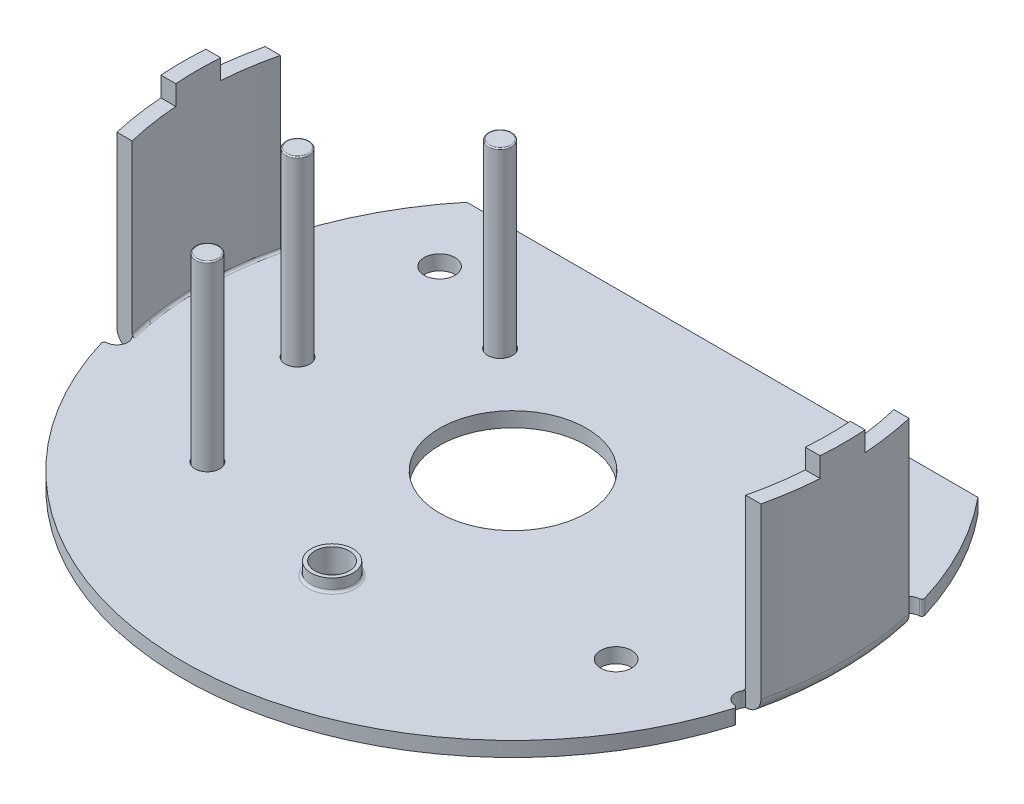
from build123d import *

# Parameters (mm, degrees)
SKETCH_1_R          = 13.375
EXTRUDE_1_DEPTH     = 7.85
SHELL_1_T           = -0.6
CUT_EXTRUDE_1_REACH = 22.479
SKETCH_2_W          = 26.75
SKETCH_2_H          = 5.525
SKETCH_3_W          = 26.75
SKETCH_3_H          = 6.475
SKETCH_3_H_2        = 11.375
CUT_EXTRUDE_2_DEPTH = 7.25
CUT_EXTRUDE_3_DEPTH = 0.6
FILLET_1_R          = 0.1
FILLET_2_R          = 0.6
FILLET_3_R          = 0.1
SKETCH_5_R          = 2.975
SKETCH_5_R_2        = 0.625
SKETCH_5_R_3        = 0.5
SKETCH_5_R_4        = 0.7
CUT_EXTRUDE_4_DEPTH = 0.6
SKETCH_6_R          = 1.1
CUT_EXTRUDE_5_DEPTH = 0.1
SKETCH_7_R          = 0.475
EXTRUDE_2_DEPTH     = 7.95
EXTRUDE_2_2_DEPTH   = 7.95
EXTRUDE_2_3_DEPTH   = 7.95
FILLET_4_R          = 0.05
FILLET_5_R          = 0.05
FILLET_6_R          = 0.05
SKETCH_8_W          = 26.75
SKETCH_8_H          = 2.19
CUT_EXTRUDE_6_DEPTH = 0.4
EXTRUDE_3_DEPTH     = 0.4
SKETCH_10_R         = 0.85
SKETCH_10_R_2       = 0.7
EXTRUDE_4_DEPTH     = 0.5
FILLET_7_R          = 0.15
FILLET_8_R          = 0.1


with BuildPart() as part:
    # Эскиз1 → Бобышка-Вытянуть1 (new body)
    with BuildSketch(Plane(origin=(0, 0, 0), x_dir=(1, 0, 0), z_dir=(0, 1, 0))):
        with Locations(Location((0, 0, 0), (0, 0, 270))):
            Circle(SKETCH_1_R)
    extrude(amount=EXTRUDE_1_DEPTH)

    # Оболочка1
    shell_1_openings = [part.faces().sort_by_distance(p)[0] for p in [
        (0, 7.85, 0),
    ]]
    offset(amount=SHELL_1_T, openings=shell_1_openings, kind=Kind.INTERSECTION)

    # Вырез-Вытянуть1: up to this face of the body (flat: up to its plane)
    cut_extrude_1_end = Plane(part.part.faces().sort_by_distance((0, 0, 0))[0])
    # Эскиз2 → Вырез-Вытянуть1 (cut, up to the picked face)
    with BuildSketch(Plane(origin=(0, 7.85, 0), x_dir=(1, 0, 0), z_dir=(0, 1, 0)), mode=Mode.PRIVATE) as cut_extrude_1_sk1:
        with Locations((0, 11.2375)):
            Rectangle(SKETCH_2_W, SKETCH_2_H)
    cut_extrude_1_tool1 = split(extrude(cut_extrude_1_sk1.sketch, amount=-CUT_EXTRUDE_1_REACH, mode=Mode.PRIVATE), bisect_by=cut_extrude_1_end, keep=Keep.BOTH, mode=Mode.PRIVATE)
    add(cut_extrude_1_tool1.solids().sort_by(Axis((0, 7.85, -11.2375), (0, -1, 0)))[0], mode=Mode.SUBTRACT)

    # Эскиз3 → Вырез-Вытянуть2 (cut)
    with BuildSketch(Plane(origin=(0, 7.85, 0), x_dir=(1, 0, 0), z_dir=(0, 1, 0))):
        with Locations((0, 6.2375)):
            Rectangle(SKETCH_3_W, SKETCH_3_H)
        with Locations((0, -8.6875)):
            Rectangle(SKETCH_3_W, SKETCH_3_H_2)
    extrude(amount=-CUT_EXTRUDE_2_DEPTH, mode=Mode.SUBTRACT)

    # Эскиз4 → Вырез-Вытянуть3 (cut)
    with BuildSketch(Plane(origin=(0, 0.6, 0), x_dir=(1, 0, 0), z_dir=(0, 1, 0))):
        with BuildLine():
            Line((-13.03421, -3), (-12.417754, -3))
            ThreePointArc((-12.417754, -3), (-12.359475, -3.522974), (-12.846906, -3.721241))
            ThreePointArc((-12.846906, -3.721241), (-12.945582, -3.361925), (-13.03421, -3))
        make_face()
        with BuildLine():
            Line((-13.03421, 3), (-12.417754, 3))
            ThreePointArc((-12.417754, 3), (-12.359475, 3.522974), (-12.846906, 3.721241))
            ThreePointArc((-12.846906, 3.721241), (-12.945582, 3.361925), (-13.03421, 3))
        make_face()
    cut_extrude_3 = extrude(amount=-CUT_EXTRUDE_3_DEPTH, mode=Mode.SUBTRACT)

    # Зеркальное отражение1: Вырез-Вытянуть3 across plane
    add(cut_extrude_3.mirror(Plane(origin=(0, 0, 0), x_dir=(0, 0, 1), z_dir=(1, 0, 0))), mode=Mode.SUBTRACT)

    # Скругление1
    fillet_1_edges = [part.edges().sort_by_distance(p)[0] for p in [
        (12.846906, 0.3, -3.721241),
        (12.846906, 0.3, 3.721241),
        (-12.846906, 0.3, -3.721241),
        (-12.846906, 0.3, 3.721241),
    ]]
    fillet(fillet_1_edges, radius=FILLET_1_R)

    # Скругление2
    fillet_2_edges = [part.edges().sort_by_distance(p)[0] for p in [
        (-13.375, 0, 0),
        (13.375, 0, 0),
    ]]
    fillet(fillet_2_edges, radius=FILLET_2_R)

    # Скругление3
    fillet_3_edges = [part.edges().sort_by_distance(p)[0] for p in [
        (-12.775, 0.6, 0),
        (12.775, 0.6, 0),
    ]]
    fillet(fillet_3_edges, radius=FILLET_3_R)

    # Эскиз5 → Вырез-Вытянуть4 (cut)
    with BuildSketch(Plane(origin=(0, 0.6, 0), x_dir=(1, 0, 0), z_dir=(0, 1, 0))):
        with Locations(Location((0, 0, 0), (0, 0, 270))):
            Circle(SKETCH_5_R)
        with Locations(Location((-8.647222, 5.675, 0), (0, 0, 270))):
            Circle(SKETCH_5_R_2)
        with Locations(Location((-4.547222, 4.025, 0), (0, 0, 270))):
            Circle(SKETCH_5_R_3)
        with Locations(Location((-8.347222, -0.375, 0), (0, 0, 270))):
            Circle(SKETCH_5_R_3)
        with Locations(Location((-6.497222, -5.875, 0), (0, 0, 270))):
            Circle(SKETCH_5_R_3)
        with Locations(Location((0, -7.325, 0), (0, 0, 270))):
            Circle(SKETCH_5_R_4)
        with Locations(Location((8.697222, -4.525, 0), (0, 0, 270))):
            Circle(SKETCH_5_R_2)
    extrude(amount=-CUT_EXTRUDE_4_DEPTH, mode=Mode.SUBTRACT)

    # Эскиз6 → Вырез-Вытянуть5 (cut)
    with BuildSketch(Plane.XZ):
        with Locations(Location((-6.497222, 5.875, 0), (0, 0, 270))):
            Circle(SKETCH_6_R)
        with Locations(Location((-8.347222, 0.375, 0), (0, 0, 270))):
            Circle(SKETCH_6_R)
        with Locations(Location((-4.547222, -4.025, 0), (0, 0, 270))):
            Circle(SKETCH_6_R)
    extrude(amount=-CUT_EXTRUDE_5_DEPTH, mode=Mode.SUBTRACT)

    # Эскиз8 → Вырез-Вытянуть6 (cut)
    with BuildSketch(Plane(origin=(0, 7.85, 0), x_dir=(1, 0, 0), z_dir=(0, 1, 0))):
        with Locations((0, 2.005)):
            Rectangle(SKETCH_8_W, SKETCH_8_H)
        with Locations((0, -2.005)):
            Rectangle(SKETCH_8_W, SKETCH_8_H)
    extrude(amount=-CUT_EXTRUDE_6_DEPTH, mode=Mode.SUBTRACT)

    # Эскиз9 → Бобышка-Вытянуть3 (add)
    with BuildSketch(Plane(origin=(0, 7.85, 0), x_dir=(1, 0, 0), z_dir=(0, 1, 0))):
        with BuildLine():
            Line((-13.344007, -0.91), (-12.742548, -0.91))
            ThreePointArc((-12.742548, -0.91), (-12.775, 0), (-12.742548, 0.91))
            Line((-12.742548, 0.91), (-13.344007, 0.91))
            ThreePointArc((-13.344007, 0.91), (-13.375, 0), (-13.344007, -0.91))
        make_face()
        with BuildLine():
            Line((12.742548, -0.91), (13.344007, -0.91))
            ThreePointArc((13.344007, -0.91), (13.375, 0), (13.344007, 0.91))
            Line((13.344007, 0.91), (12.742548, 0.91))
            ThreePointArc((12.742548, 0.91), (12.775, 0), (12.742548, -0.91))
        make_face()
    extrude(amount=EXTRUDE_3_DEPTH)

    # Эскиз10 → Бобышка-Вытянуть4 (add)
    with BuildSketch(Plane(origin=(0, 0.6, 0), x_dir=(1, 0, 0), z_dir=(0, 1, 0))):
        with Locations(Location((0, -7.325, 0), (0, 0, 270))):
            Circle(SKETCH_10_R)
        with Locations(Location((0, -7.325, 0), (0, 0, 270))):
            Circle(SKETCH_10_R_2, mode=Mode.SUBTRACT)
    extrude(amount=EXTRUDE_4_DEPTH)

    # Скругление7
    fillet_7_edges = [part.edges().sort_by_distance(p)[0] for p in [
        (0, 0, 6.625),
    ]]
    fillet(fillet_7_edges, radius=FILLET_7_R)

    # Скругление8
    fillet_8_edges = [part.edges().sort_by_distance(p)[0] for p in [
        (0, 0.6, 6.475),
    ]]
    fillet(fillet_8_edges, radius=FILLET_8_R)


with BuildPart() as body_2:
    # Эскиз7 → Бобышка-Вытянуть2 (new body)
    with BuildSketch(Plane.XZ):
        with Locations(Location((-6.497222, 5.875, 0), (0, 0, 270))):
            Circle(SKETCH_7_R)
    extrude(amount=-EXTRUDE_2_DEPTH)

    # Скругление6
    fillet_6_edges = [body_2.edges().sort_by_distance(p)[0] for p in [
        (-6.497222, 0, 6.35),
        (-6.497222, 7.95, 6.35),
    ]]
    fillet(fillet_6_edges, radius=FILLET_6_R)


with BuildPart() as body_3:
    # Эскиз7 → Extrude 2 2 (new body)
    with BuildSketch(Plane.XZ):
        with Locations(Location((-8.347222, 0.375, 0), (0, 0, 270))):
            Circle(SKETCH_7_R)
    extrude(amount=-EXTRUDE_2_2_DEPTH)

    # Скругление5
    fillet_5_edges = [body_3.edges().sort_by_distance(p)[0] for p in [
        (-8.347222, 0, 0.85),
        (-8.347222, 7.95, 0.85),
    ]]
    fillet(fillet_5_edges, radius=FILLET_5_R)


with BuildPart() as body_4:
    # Эскиз7 → Extrude 2 3 (new body)
    with BuildSketch(Plane.XZ):
        with Locations(Location((-4.547222, -4.025, 0), (0, 0, 270))):
            Circle(SKETCH_7_R)
    extrude(amount=-EXTRUDE_2_3_DEPTH)

    # Скругление4
    fillet_4_edges = [body_4.edges().sort_by_distance(p)[0] for p in [
        (-4.547222, 0, -3.55),
        (-4.547222, 7.95, -3.55),
    ]]
    fillet(fillet_4_edges, radius=FILLET_4_R)


solid = Compound([part.part, body_2.part, body_3.part, body_4.part])
